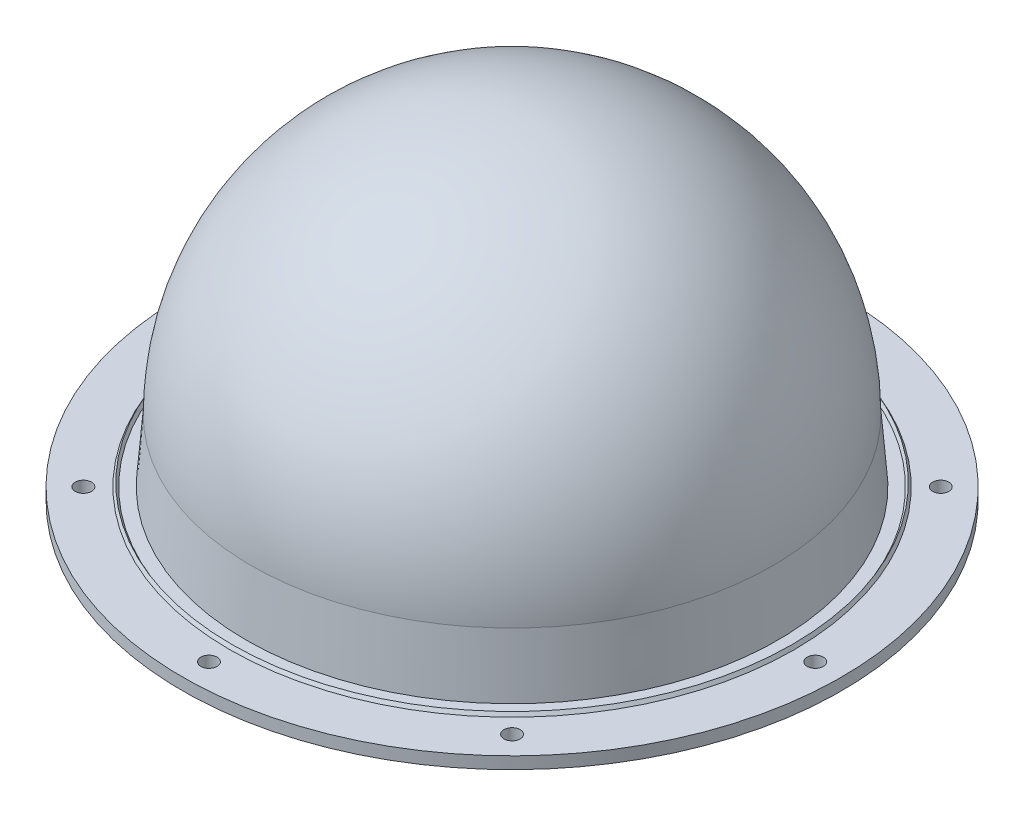
from build123d import *

# Parameters (mm, degrees)
SKETCH_2_R               = 2.3
CUT_EXTRUDE_1_DEPTH      = 10
PATTERN_CIRCULAR_1_COUNT = 8


with BuildPart() as part:
    # 草图1 → 旋转1 (revolve)
    with BuildSketch(Plane.XY):
        Polygon((-93.5, 3.4), (-93.5, 0), (-73.1, 0), (-71.429545455, 21), (-74, 21), (-75.4, 3.4), align=None)
        with BuildLine():
            ThreePointArc((0, 92.429545455), (-50.508315968, 71.508315968), (-71.429545455, 21))
            Line((-71.429545455, 21), (-74, 21))
            ThreePointArc((-74, 21), (-52.325901808, 73.325901808), (0, 95))
            Line((0, 95), (0, 92.429545455))
        make_face()
        Polygon((-79.5, 4.4), (-80.077350269, 3.4), (-78.922649731, 3.4), align=None)
    revolve(axis=Axis((0, 0, 0), (0, 1, 0)))

    # 草图2 → 切除-拉伸1 (cut)
    with BuildSketch(Plane(origin=(0, 3.4, 0), x_dir=(1, 0, 0), z_dir=(0, 1, 0))):
        with Locations((0, 86)):
            Circle(SKETCH_2_R)
    cut_extrude_1 = extrude(amount=-CUT_EXTRUDE_1_DEPTH, mode=Mode.SUBTRACT)

    # 阵列(圆周)1: 切除-拉伸1 ×8 about axis
    pattern_circular_1_axis = Axis((0, 0, 0), (0, 1, 0))
    for i in range(1, PATTERN_CIRCULAR_1_COUNT):
        add(cut_extrude_1.rotate(pattern_circular_1_axis, i * 360 / PATTERN_CIRCULAR_1_COUNT), mode=Mode.SUBTRACT)


solid = part.part
